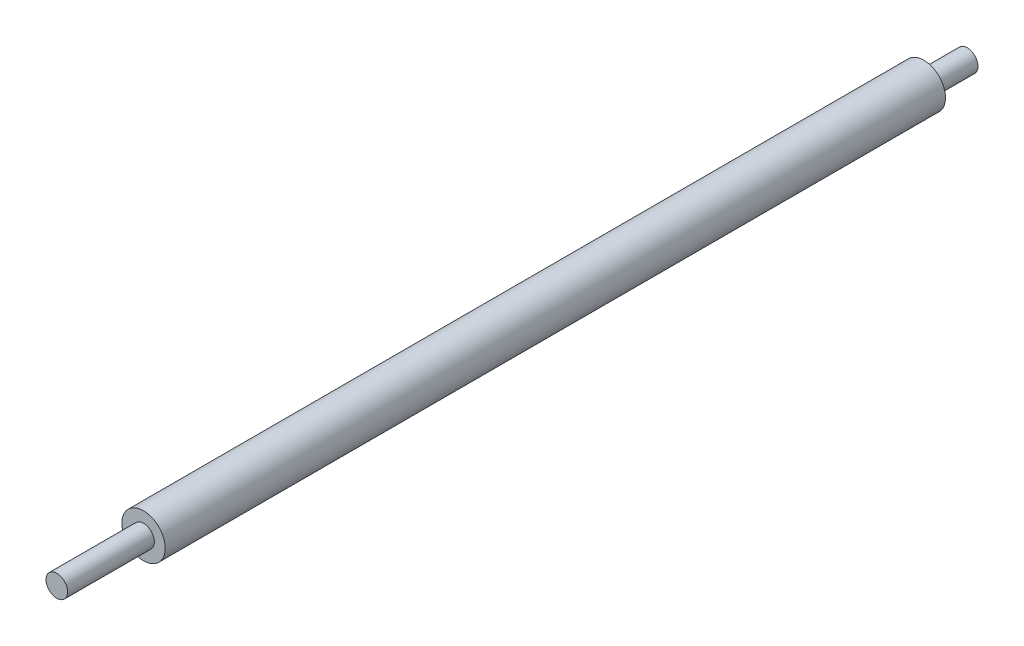
from build123d import *

# Parameters (mm, degrees)
SKETCH1_R           = 5
BOSS_EXTRUDE1_DEPTH = 180
SKETCH2_R           = 2.5
BOSS_EXTRUDE2_DEPTH = 20
SKETCH3_R           = 2.5
BOSS_EXTRUDE3_DEPTH = 10


with BuildPart() as part:
    # Sketch1 → Boss-Extrude1 (new body)
    with BuildSketch(Plane.XY):
        Circle(SKETCH1_R)
    extrude(amount=BOSS_EXTRUDE1_DEPTH)

    # Sketch2 → Boss-Extrude2 (add)
    with BuildSketch(Plane.XY.offset(180)):
        Circle(SKETCH2_R)
    extrude(amount=BOSS_EXTRUDE2_DEPTH)

    # Sketch3 → Boss-Extrude3 (add)
    with BuildSketch(Plane(origin=(0, 0, 0), x_dir=(-1, 0, 0), z_dir=(0, 0, -1))):
        Circle(SKETCH3_R)
    extrude(amount=BOSS_EXTRUDE3_DEPTH)


solid = part.part
